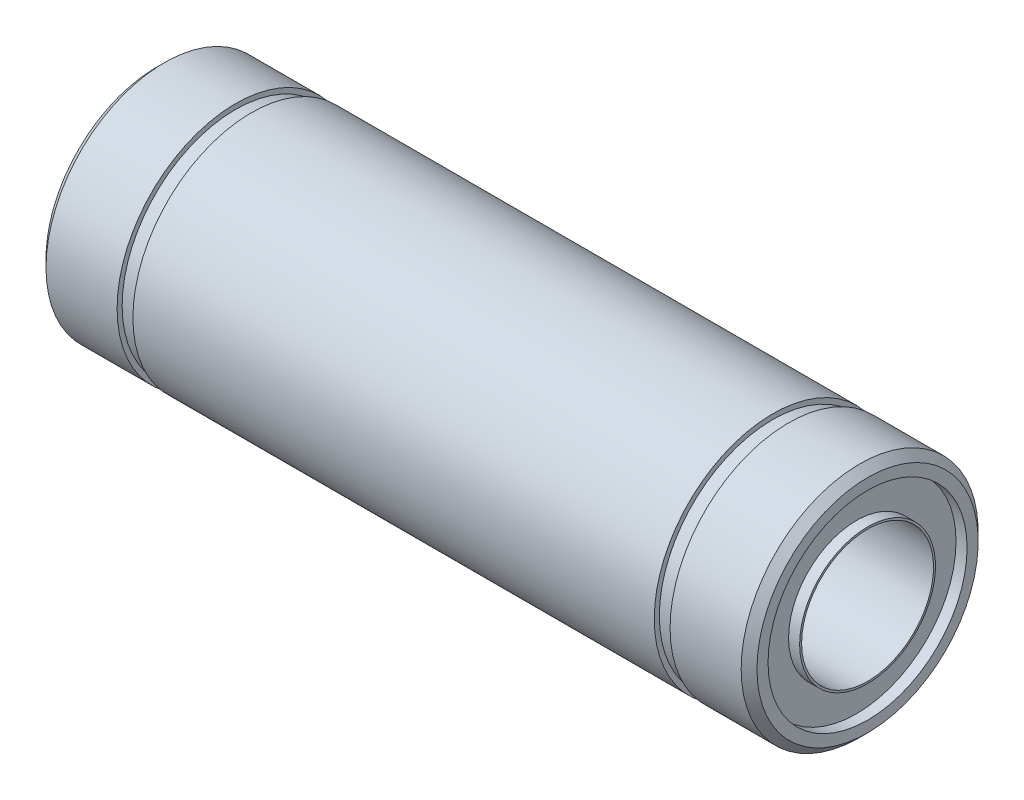
from build123d import *

# Parameters (mm, degrees)
ZKOSEN_1_SIZE = 0.5


with BuildPart() as part:
    # Skica1 → Rotovat1 (revolve)
    with BuildSketch(Plane.XY):
        Polygon((0, 4.3), (0, 4.175), (45, 4.175), (45, 4.3), (44.3, 4.3), (44.3, 6.3), (45, 6.3), (45, 7.5), (40, 7.5), (40, 7.18), (39, 7.18), (39, 7.5), (6, 7.5), (6, 7.18), (5, 7.18), (5, 7.5), (0, 7.5), (0, 6.3), (0.7, 6.3), (0.7, 4.3), align=None)
    revolve(axis=Axis((0, 0, 0), (1, 0, 0)))

    # Zkosení1
    zkosen_1_edges = [part.edges().sort_by_distance(p)[0] for p in [
        (0, -7.5, 0),
        (45, -7.5, 0),
    ]]
    chamfer(zkosen_1_edges, length=ZKOSEN_1_SIZE)


solid = part.part
